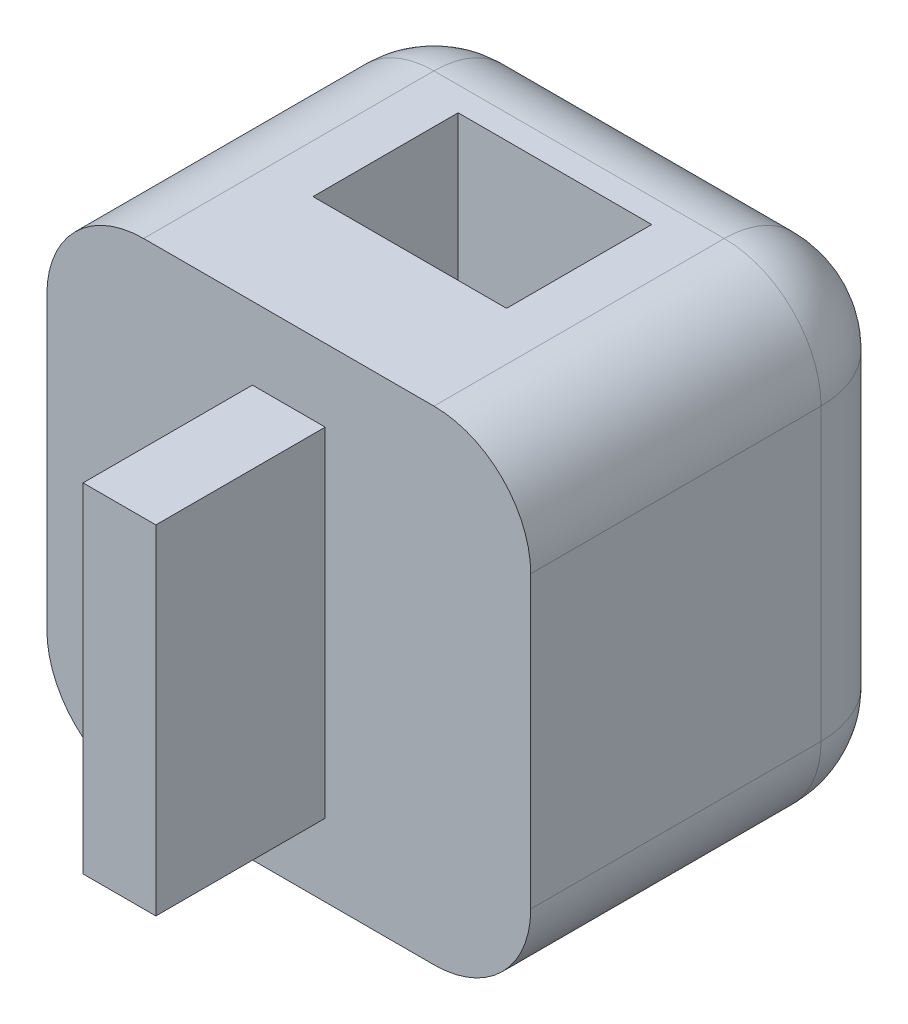
from build123d import *

# Parameters (mm, degrees)
SKETCH1_W           = 10
SKETCH1_H           = 10
BOSS_EXTRUDE1_DEPTH = 8
SKETCH2_W           = 4
SKETCH2_H           = 3
CUT_EXTRUDE1_DEPTH  = 11
SKETCH3_W           = 1.504859188
SKETCH3_H           = 7
BOSS_EXTRUDE2_DEPTH = 3.5
FILLET1_R           = 2


with BuildPart() as part:
    # Sketch1 → Boss-Extrude1 (new body)
    with BuildSketch(Plane.XY):
        Rectangle(SKETCH1_W, SKETCH1_H)
    extrude(amount=BOSS_EXTRUDE1_DEPTH)

    # Sketch2 → Cut-Extrude1 (cut, through all)
    with BuildSketch(Plane.XZ.offset(5)):
        with Locations((0, 4)):
            Rectangle(SKETCH2_W, SKETCH2_H)
    extrude(amount=-CUT_EXTRUDE1_DEPTH, mode=Mode.SUBTRACT)

    # Sketch3 → Boss-Extrude2 (add)
    with BuildSketch(Plane.XY.offset(8)):
        Rectangle(SKETCH3_W, SKETCH3_H)
    extrude(amount=BOSS_EXTRUDE2_DEPTH)

    # Fillet1
    fillet1_edges = [part.edges().sort_by_distance(p)[0] for p in [
        (0, -5, 0),
        (-5, 0, 0),
        (0, 5, 0),
        (5, 0, 0),
        (5, -5, 4),
        (-5, -5, 4),
        (-5, 5, 4),
        (5, 5, 4),
    ]]
    fillet(fillet1_edges, radius=FILLET1_R)


solid = part.part
